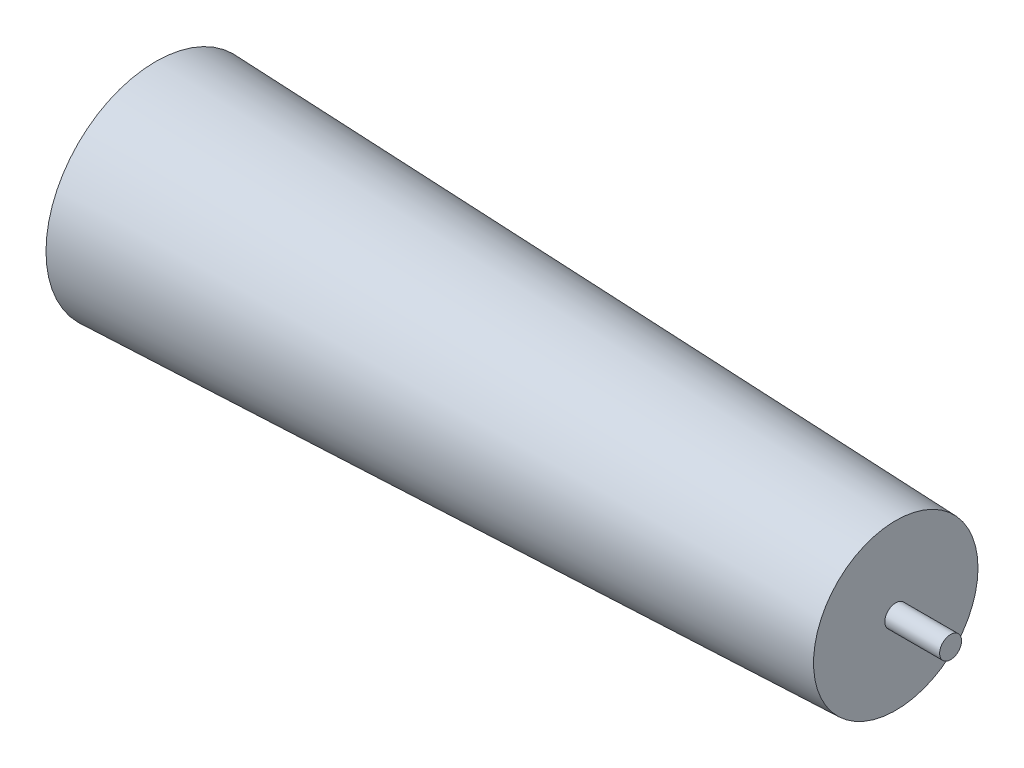
from build123d import *

# Parameters (mm, degrees)
SKETCH1_R                = 40
SKETCH2_R                = 30
SKETCH3_R                = 4
BOSS_EXTRUDE1_DEPTH      = 20
BOSS_EXTRUDE1_DEPTH_BACK = 280


with BuildPart() as part:
    # Sketch1 → Loft1 section 0
    with BuildSketch(Plane(origin=(0, 0, 0), x_dir=(0, 0, -1), z_dir=(1, 0, 0))):
        Circle(SKETCH1_R)
    # Sketch2 → Loft1 section 1
    with BuildSketch(Plane(origin=(270, 0, 0), x_dir=(0, 0, -1), z_dir=(1, 0, 0))):
        Circle(SKETCH2_R)
    loft()

    # Sketch3 → Boss-Extrude1 (add, two sides)
    with BuildSketch(Plane(origin=(270, 0, 0), x_dir=(0, 0, -1), z_dir=(1, 0, 0))) as boss_extrude1_sk:
        Circle(SKETCH3_R)
    extrude(amount=BOSS_EXTRUDE1_DEPTH)
    extrude(boss_extrude1_sk.sketch, amount=-BOSS_EXTRUDE1_DEPTH_BACK)


solid = part.part
